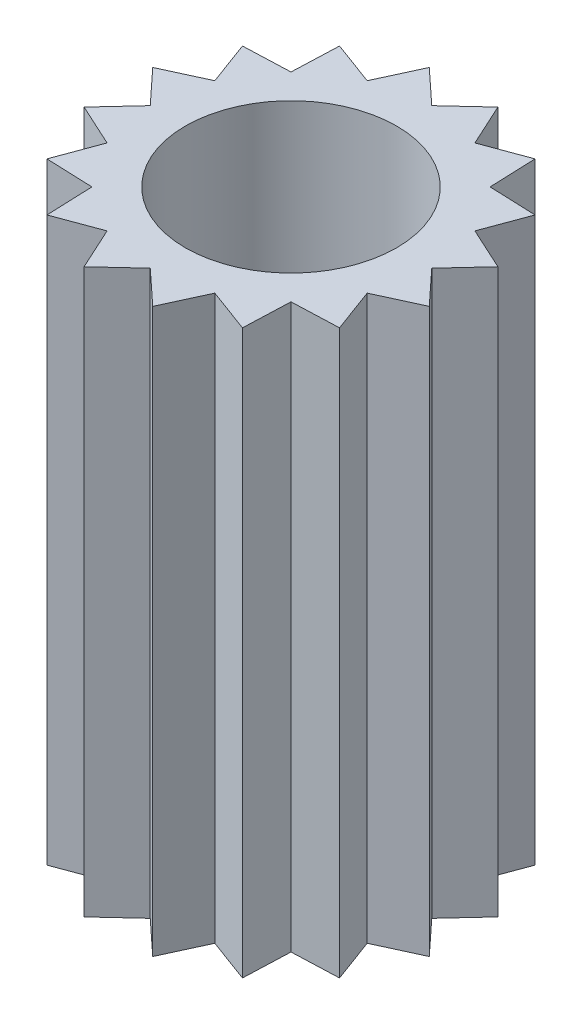
from build123d import *

# Parameters (mm, degrees)
SKETCH1_R           = 1.5
BOSS_EXTRUDE1_DEPTH = 8


with BuildPart() as part:
    # Sketch1 → Boss-Extrude1 (new body)
    with BuildSketch(Plane(origin=(0, 0, 0), x_dir=(1, 0, 0), z_dir=(0, 1, 0))):
        Polygon((0, 2), (0.487725805, 2.451963201), (0.765366865, 1.847759065), (1.388925583, 2.078674031), (1.414213562, 1.414213562), (2.078674031, 1.388925583), (1.847759065, 0.765366865), (2.451963201, 0.487725805), (2, 0), (2.451963201, -0.487725805), (1.847759065, -0.765366865), (2.078674031, -1.388925583), (1.414213562, -1.414213562), (1.388925583, -2.078674031), (0.765366865, -1.847759065), (0.487725805, -2.451963201), (0, -2), (-0.487725805, -2.451963201), (-0.765366865, -1.847759065), (-1.388925583, -2.078674031), (-1.414213562, -1.414213562), (-2.078674031, -1.388925583), (-1.847759065, -0.765366865), (-2.451963201, -0.487725805), (-2, 0), (-2.451963201, 0.487725805), (-1.847759065, 0.765366865), (-2.078674031, 1.388925583), (-1.414213562, 1.414213562), (-1.388925583, 2.078674031), (-0.765366865, 1.847759065), (-0.487725805, 2.451963201), align=None)
        Circle(SKETCH1_R, mode=Mode.SUBTRACT)
    extrude(amount=BOSS_EXTRUDE1_DEPTH)


solid = part.part
